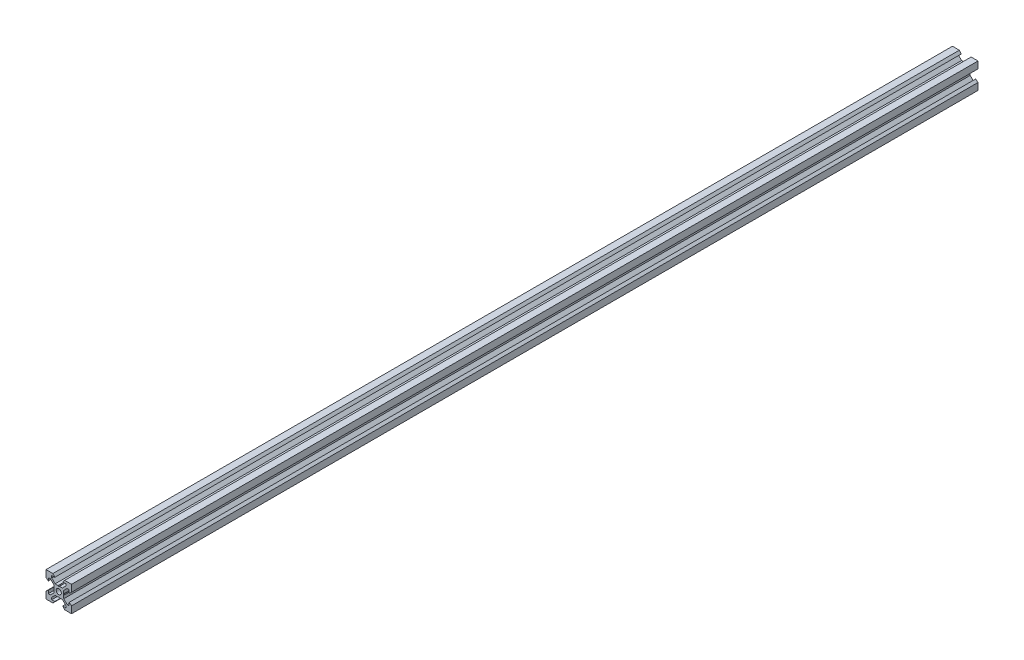
from build123d import *

# Parameters (mm, degrees)
SKETCH1_R           = 2
BOSS_EXTRUDE1_DEPTH = 355


with BuildPart() as part:
    # Sketch1 → Boss-Extrude1 (new body, symmetric)
    with BuildSketch(Plane.XY):
        Polygon((10, 10), (10, 4.610379336), (8.2, 3.1), (8.2, 5.5), (6.560660172, 5.5), (3.9, 2.839339828), (3.9, 0.519615242), (3.6, 0), (3.9, -0.519615242), (3.9, -2.839339828), (6.560660172, -5.5), (8.2, -5.5), (8.2, -3.1), (10, -4.610379336), (10, -10), (4.610379336, -10), (3.1, -8.2), (5.5, -8.2), (5.5, -6.560660172), (2.839339828, -3.9), (0.519615242, -3.9), (0, -3.6), (-0.519615242, -3.9), (-2.839339828, -3.9), (-5.5, -6.560660172), (-5.5, -8.2), (-3.1, -8.2), (-4.610379336, -10), (-10, -10), (-10, -4.610379336), (-8.2, -3.1), (-8.2, -5.5), (-6.560660172, -5.5), (-3.9, -2.839339828), (-3.9, -0.519615242), (-3.6, 0), (-3.9, 0.519615242), (-3.9, 2.839339828), (-6.560660172, 5.5), (-8.2, 5.5), (-8.2, 3.1), (-10, 4.610379336), (-10, 10), (-4.610379336, 10), (-3.1, 8.2), (-5.5, 8.2), (-5.5, 6.560660172), (-2.839339828, 3.9), (-0.519615242, 3.9), (0, 3.6), (0.519615242, 3.9), (2.839339828, 3.9), (5.5, 6.560660172), (5.5, 8.2), (3.1, 8.2), (4.610379336, 10), align=None)
        Circle(SKETCH1_R, mode=Mode.SUBTRACT)
    extrude(amount=BOSS_EXTRUDE1_DEPTH, both=True)


solid = part.part
